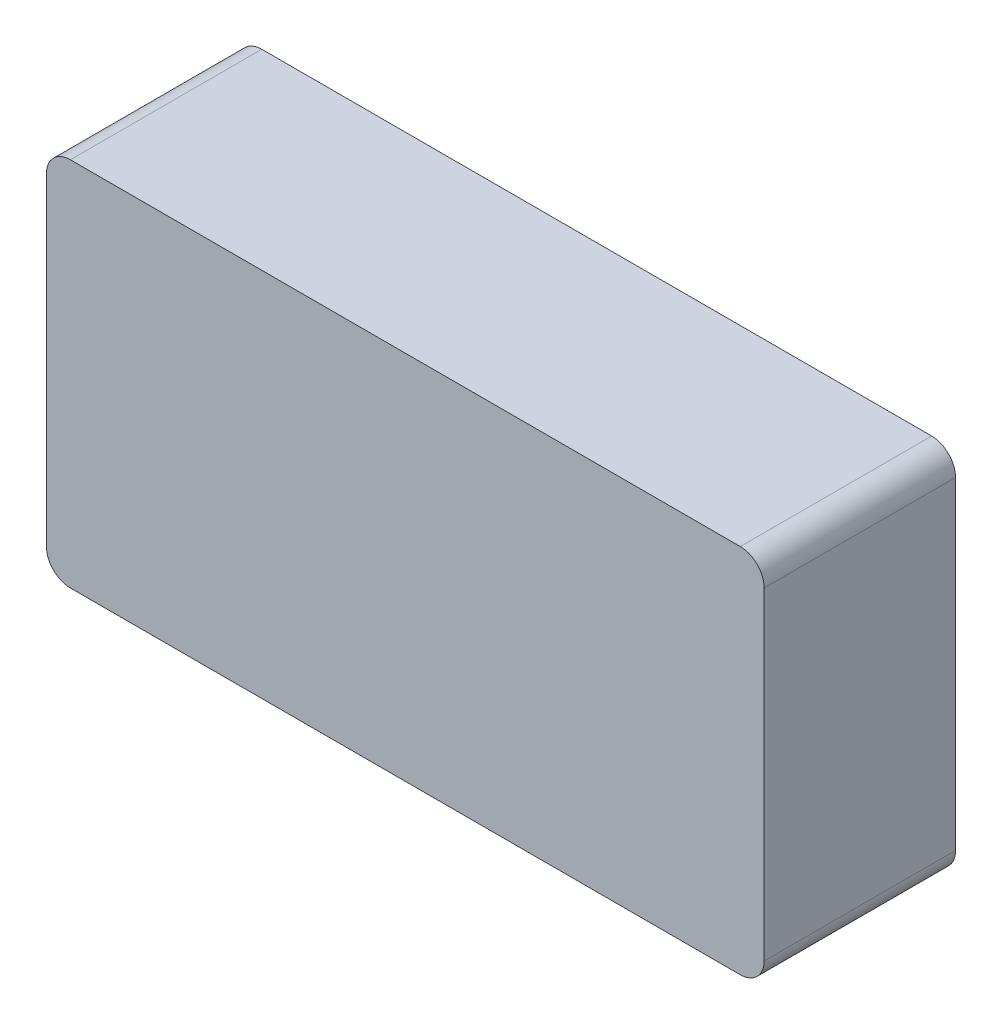
from build123d import *

# Parameters (mm, degrees)
ESBO_O1_W                = 60
ESBO_O1_H                = 31
RESSALTO_EXTRUS_O1_DEPTH = 16
FILETE1_R                = 2


with BuildPart() as part:
    # Esboço1 → Ressalto-extrusão1 (new body)
    with BuildSketch(Plane.XY):
        with Locations((30, -15.5)):
            Rectangle(ESBO_O1_W, ESBO_O1_H)
    extrude(amount=RESSALTO_EXTRUS_O1_DEPTH)

    # Filete1
    filete1_edges = [part.edges().sort_by_distance(p)[0] for p in [
        (0, 0, 8),
        (60, 0, 8),
        (60, -31, 8),
        (0, -31, 8),
    ]]
    fillet(filete1_edges, radius=FILETE1_R)


solid = part.part
